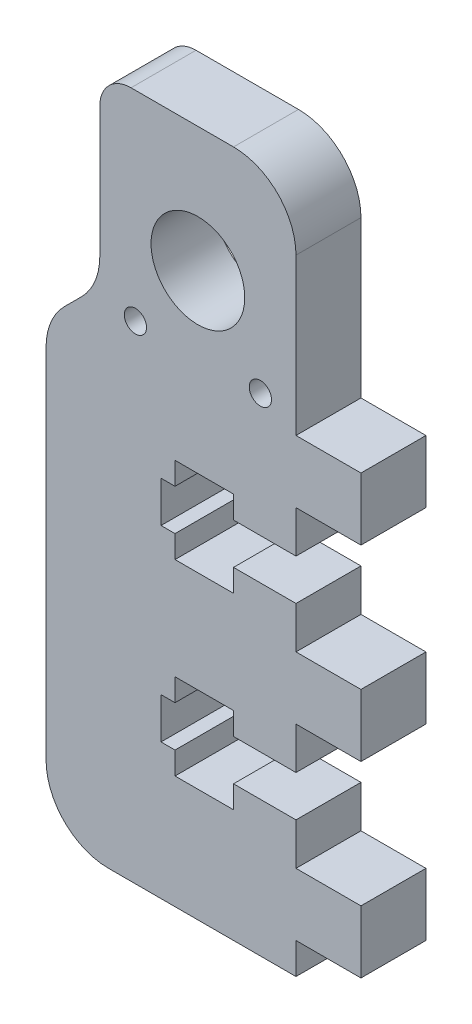
from build123d import *

# Parameters (mm, degrees)
SKETCH1_R                 = 4.7625
BOSS_EXTRUDE1_DEPTH       = 6.604
CUT_EXTRUDE1_DEPTH        = 7.604
SKETCH3_W                 = 6.604
SKETCH3_H                 = 6.35
BOSS_EXTRUDE2_DEPTH       = 6.604
FILLET1_R                 = 6.35
FILLET2_R                 = 3.175
F_4_40_TAPPED_HOLE1_D     = 2.2606
F_4_40_TAPPED_HOLE1_DEPTH = 7.5946
F_4_40_TAPPED_HOLE1_TIP   = 0.679152758


with BuildPart() as part:
    # Sketch1 → Boss-Extrude1 (new body)
    with BuildSketch(Plane.XY):
        Polygon((0, 0), (0, 69.85), (-19.939, 69.85), (-19.939, 50.8), (-25.4, 45.339), (-25.4, 0), align=None)
        with Locations((-9.9695, 57.15)):
            Circle(SKETCH1_R, mode=Mode.SUBTRACT)
    extrude(amount=BOSS_EXTRUDE1_DEPTH)

    # Sketch2 → Cut-Extrude1 (cut, through all)
    with BuildSketch(Plane.XY.offset(6.604)):
        Polygon((-12.2936, 37.0078), (-13.716, 37.0078), (-13.716, 32.8422), (-12.2936, 32.8422), (-12.2936, 30.5562), (-6.35, 30.5562), (-6.35, 32.8422), (0, 32.8422), (0, 37.0078), (-6.35, 37.0078), (-6.35, 39.2938), (-12.2936, 39.2938), align=None)
        Polygon((-12.2936, 20.2438), (-12.2936, 17.9578), (-13.716, 17.9578), (-13.716, 13.7922), (-12.2936, 13.7922), (-12.2936, 11.5062), (-6.35, 11.5062), (-6.35, 13.7922), (0, 13.7922), (0, 17.9578), (-6.35, 17.9578), (-6.35, 20.2438), align=None)
    extrude(amount=-CUT_EXTRUDE1_DEPTH, mode=Mode.SUBTRACT)

    # Sketch3 → Boss-Extrude2 (add)
    with BuildSketch(Plane.XY.offset(6.604)):
        with Locations((3.302, 44.45)):
            Rectangle(SKETCH3_W, SKETCH3_H)
        with Locations((3.302, 25.4)):
            Rectangle(SKETCH3_W, SKETCH3_H)
        with Locations((3.302, 6.35)):
            Rectangle(SKETCH3_W, SKETCH3_H)
    extrude(amount=-BOSS_EXTRUDE2_DEPTH)

    # Fillet1
    fillet1_edges = [part.edges().sort_by_distance(p)[0] for p in [
        (-25.4, 0, 3.302),
        (-25.4, 45.339, 3.302),
        (-19.939, 50.8, 3.302),
        (0, 69.85, 3.302),
    ]]
    fillet(fillet1_edges, radius=FILLET1_R)

    # Fillet2
    fillet2_edges = [part.edges().sort_by_distance(p)[0] for p in [
        (-19.939, 69.85, 3.302),
    ]]
    fillet(fillet2_edges, radius=FILLET2_R)

    # #4-40 Tapped Hole1
    with Locations(Plane.XY.offset(6.604)):
        with Locations((-3.6195, 49.53), (-16.3195, 49.53)):
            Hole(F_4_40_TAPPED_HOLE1_D / 2, depth=F_4_40_TAPPED_HOLE1_DEPTH)
            with Locations((0, 0, -(F_4_40_TAPPED_HOLE1_DEPTH + F_4_40_TAPPED_HOLE1_TIP / 2))):  # 118° drill point
                Cone(0, F_4_40_TAPPED_HOLE1_D / 2, F_4_40_TAPPED_HOLE1_TIP, mode=Mode.SUBTRACT)


solid = part.part
